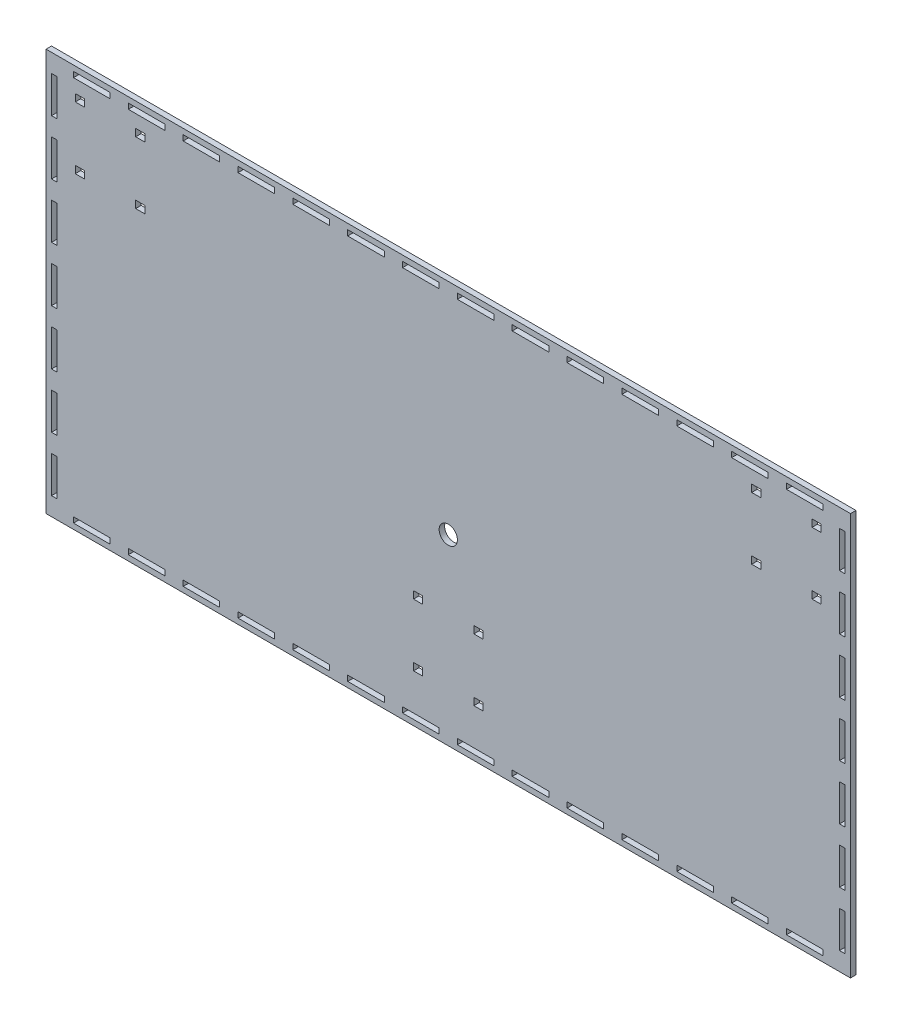
from build123d import *

# Parameters (mm, degrees)
ESQUISSE1_W             = 440
ESQUISSE1_H             = 220
BOSS_EXTRU_1_DEPTH      = 3
ESQUISSE2_R             = 5
ENL_V_MAT_EXTRU_1_DEPTH = 3
ESQUISSE3_W             = 5
ESQUISSE3_H             = 4
ENL_V_MAT_EXTRU_2_DEPTH = 3
ESQUISSE4_W             = 20
ESQUISSE4_H             = 3
ENL_V_MAT_EXTRU_3_DEPTH = 3
ESQUISSE5_W             = 3
ESQUISSE5_H             = 20
ENL_V_MAT_EXTRU_4_DEPTH = 3


with BuildPart() as part:
    # Esquisse1 → Boss.-Extru.1 (new body)
    with BuildSketch(Plane.XY):
        Rectangle(ESQUISSE1_W, ESQUISSE1_H)
    extrude(amount=BOSS_EXTRU_1_DEPTH)

    # Esquisse2 → Enlèv. mat.-Extru.1 (cut)
    with BuildSketch(Plane.XY.offset(3)):
        with Locations((0, -10)):
            Circle(ESQUISSE2_R)
    extrude(amount=-ENL_V_MAT_EXTRU_1_DEPTH, mode=Mode.SUBTRACT)

    # Esquisse3 → Enlèv. mat.-Extru.2 (cut)
    with BuildSketch(Plane.XY.offset(3)):
        with Locations((-201.5, 95)):
            Rectangle(ESQUISSE3_W, ESQUISSE3_H)
        with Locations((-168.5, 95)):
            Rectangle(ESQUISSE3_W, ESQUISSE3_H)
        with Locations((-168.5, 61)):
            Rectangle(ESQUISSE3_W, ESQUISSE3_H)
        with Locations((-201.5, 61)):
            Rectangle(ESQUISSE3_W, ESQUISSE3_H)
        with Locations((168.5, 61)):
            Rectangle(ESQUISSE3_W, ESQUISSE3_H)
        with Locations((201.5, 61)):
            Rectangle(ESQUISSE3_W, ESQUISSE3_H)
        with Locations((168.5, 95)):
            Rectangle(ESQUISSE3_W, ESQUISSE3_H)
        with Locations((201.5, 95)):
            Rectangle(ESQUISSE3_W, ESQUISSE3_H)
        with Locations((-16.5, -48)):
            Rectangle(ESQUISSE3_W, ESQUISSE3_H)
        with Locations((16.5, -48)):
            Rectangle(ESQUISSE3_W, ESQUISSE3_H)
        with Locations((16.5, -82)):
            Rectangle(ESQUISSE3_W, ESQUISSE3_H)
        with Locations((-16.5, -82)):
            Rectangle(ESQUISSE3_W, ESQUISSE3_H)
    extrude(amount=-ENL_V_MAT_EXTRU_2_DEPTH, mode=Mode.SUBTRACT)

    # Esquisse4 → Enlèv. mat.-Extru.3 (cut)
    with BuildSketch(Plane.XY.offset(3)):
        with Locations((-195, 105.5)):
            Rectangle(ESQUISSE4_W, ESQUISSE4_H)
        with Locations((-165, 105.5)):
            Rectangle(ESQUISSE4_W, ESQUISSE4_H)
        with Locations((-135, 105.5)):
            Rectangle(ESQUISSE4_W, ESQUISSE4_H)
        with Locations((-105, 105.5)):
            Rectangle(ESQUISSE4_W, ESQUISSE4_H)
        with Locations((-75, 105.5)):
            Rectangle(ESQUISSE4_W, ESQUISSE4_H)
        with Locations((-45, 105.5)):
            Rectangle(ESQUISSE4_W, ESQUISSE4_H)
        with Locations((-15, 105.5)):
            Rectangle(ESQUISSE4_W, ESQUISSE4_H)
        with Locations((15, 105.5)):
            Rectangle(ESQUISSE4_W, ESQUISSE4_H)
        with Locations((45, 105.5)):
            Rectangle(ESQUISSE4_W, ESQUISSE4_H)
        with Locations((75, 105.5)):
            Rectangle(ESQUISSE4_W, ESQUISSE4_H)
        with Locations((105, 105.5)):
            Rectangle(ESQUISSE4_W, ESQUISSE4_H)
        with Locations((135, 105.5)):
            Rectangle(ESQUISSE4_W, ESQUISSE4_H)
        with Locations((165, 105.5)):
            Rectangle(ESQUISSE4_W, ESQUISSE4_H)
        with Locations((195, 105.5)):
            Rectangle(ESQUISSE4_W, ESQUISSE4_H)
        with Locations((195, -105.5)):
            Rectangle(ESQUISSE4_W, ESQUISSE4_H)
        with Locations((165, -105.5)):
            Rectangle(ESQUISSE4_W, ESQUISSE4_H)
        with Locations((135, -105.5)):
            Rectangle(ESQUISSE4_W, ESQUISSE4_H)
        with Locations((105, -105.5)):
            Rectangle(ESQUISSE4_W, ESQUISSE4_H)
        with Locations((75, -105.5)):
            Rectangle(ESQUISSE4_W, ESQUISSE4_H)
        with Locations((45, -105.5)):
            Rectangle(ESQUISSE4_W, ESQUISSE4_H)
        with Locations((15, -105.5)):
            Rectangle(ESQUISSE4_W, ESQUISSE4_H)
        with Locations((-15, -105.5)):
            Rectangle(ESQUISSE4_W, ESQUISSE4_H)
        with Locations((-45, -105.5)):
            Rectangle(ESQUISSE4_W, ESQUISSE4_H)
        with Locations((-75, -105.5)):
            Rectangle(ESQUISSE4_W, ESQUISSE4_H)
        with Locations((-105, -105.5)):
            Rectangle(ESQUISSE4_W, ESQUISSE4_H)
        with Locations((-135, -105.5)):
            Rectangle(ESQUISSE4_W, ESQUISSE4_H)
        with Locations((-165, -105.5)):
            Rectangle(ESQUISSE4_W, ESQUISSE4_H)
        with Locations((-195, -105.5)):
            Rectangle(ESQUISSE4_W, ESQUISSE4_H)
    extrude(amount=-ENL_V_MAT_EXTRU_3_DEPTH, mode=Mode.SUBTRACT)

    # Esquisse5 → Enlèv. mat.-Extru.4 (cut)
    with BuildSketch(Plane.XY.offset(3)):
        with Locations((-215.5, -90)):
            Rectangle(ESQUISSE5_W, ESQUISSE5_H)
        with Locations((-215.5, -60)):
            Rectangle(ESQUISSE5_W, ESQUISSE5_H)
        with Locations((-215.5, -30)):
            Rectangle(ESQUISSE5_W, ESQUISSE5_H)
        with Locations((-215.5, 0)):
            Rectangle(ESQUISSE5_W, ESQUISSE5_H)
        with Locations((-215.5, 30)):
            Rectangle(ESQUISSE5_W, ESQUISSE5_H)
        with Locations((-215.5, 60)):
            Rectangle(ESQUISSE5_W, ESQUISSE5_H)
        with Locations((-215.5, 90)):
            Rectangle(ESQUISSE5_W, ESQUISSE5_H)
        with Locations((215.5, 90)):
            Rectangle(ESQUISSE5_W, ESQUISSE5_H)
        with Locations((215.5, 60)):
            Rectangle(ESQUISSE5_W, ESQUISSE5_H)
        with Locations((215.5, 30)):
            Rectangle(ESQUISSE5_W, ESQUISSE5_H)
        with Locations((215.5, 0)):
            Rectangle(ESQUISSE5_W, ESQUISSE5_H)
        with Locations((215.5, -30)):
            Rectangle(ESQUISSE5_W, ESQUISSE5_H)
        with Locations((215.5, -60)):
            Rectangle(ESQUISSE5_W, ESQUISSE5_H)
        with Locations((215.5, -90)):
            Rectangle(ESQUISSE5_W, ESQUISSE5_H)
    extrude(amount=-ENL_V_MAT_EXTRU_4_DEPTH, mode=Mode.SUBTRACT)


solid = part.part
